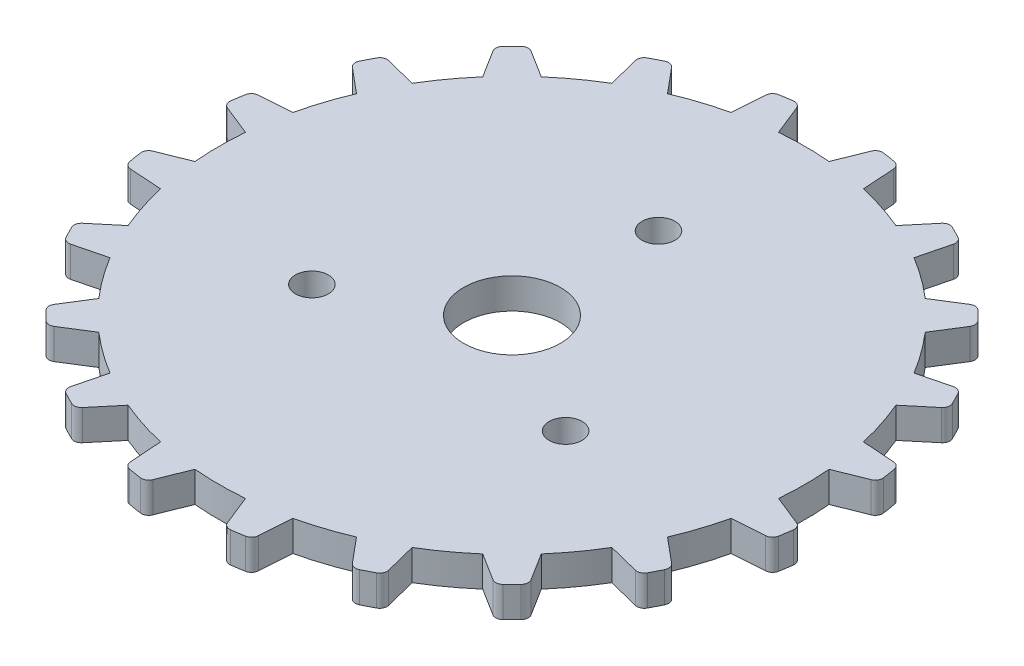
from build123d import *

# Parameters (mm, degrees)
BOSS_EXTRUDE1_DEPTH = 2.5
FILLET1_R           = 0.6
SKETCH5_R           = 1.35
CUT_EXTRUDE4_DEPTH  = 3.5
SKETCH6_R           = 3.96875
CUT_EXTRUDE5_DEPTH  = 3.5


with BuildPart() as part:
    # Sketch1 → Boss-Extrude1 (new body)
    with BuildSketch(Plane(origin=(0, 0, 0), x_dir=(1, 0, 0), z_dir=(0, 1, 0))):
        with BuildLine():
            Line((-2.069685574, 23.903244449), (-3.232226288, 26.798460531))
            ThreePointArc((-3.232226288, 26.798460531), (-4.222590109, 26.66035458), (-5.207159099, 26.485661549))
            Line((-5.207159099, 26.485661549), (-5.418128963, 23.372902518))
            ThreePointArc((-5.418128963, 23.372902518), (-7.414149843, 22.818393363), (-9.354896707, 22.093768379))
            Line((-9.354896707, 22.093768379), (-11.3552096, 24.488037662))
            ThreePointArc((-11.3552096, 24.488037662), (-12.25442448, 24.050651847), (-13.136822119, 23.580260351))
            Line((-13.136822119, 23.580260351), (-12.375570942, 20.554657318))
            ThreePointArc((-12.375570942, 20.554657318), (-14.102546855, 19.410483399), (-15.724385372, 18.121600323))
            Line((-15.724385372, 18.121600323), (-18.36666588, 19.780555048))
            ThreePointArc((-18.36666588, 19.780555048), (-19.086710402, 19.086703739), (-19.78056146, 18.366658976))
            Line((-19.78056146, 18.366658976), (-18.121605812, 15.724379046))
            ThreePointArc((-18.121605812, 15.724379046), (-19.410488322, 14.102540079), (-20.554661637, 12.375563767))
            Line((-20.554661637, 12.375563767), (-23.580264936, 13.136813888))
            ThreePointArc((-23.580264936, 13.136813888), (-24.050656124, 12.254416085), (-24.488041625, 11.355201052))
            Line((-24.488041625, 11.355201052), (-22.093771644, 9.354888995))
            ThreePointArc((-22.093771644, 9.354888995), (-22.818395951, 7.414141878), (-23.37290441, 5.418120804))
            Line((-23.37290441, 5.418120804), (-26.485663367, 5.207149854))
            ThreePointArc((-26.485663367, 5.207149854), (-26.660356054, 4.222580803), (-26.798461659, 3.232216933))
            Line((-26.798461659, 3.232216933), (-23.903245172, 2.06967723))
            ThreePointArc((-23.903245172, 2.06967723), (-23.99268, -4.188e-06), (-23.903244449, -2.069685574))
            Line((-23.903244449, -2.069685574), (-26.798460531, -3.232226288))
            ThreePointArc((-26.798460531, -3.232226288), (-26.66035458, -4.222590109), (-26.485661549, -5.207159099))
            Line((-26.485661549, -5.207159099), (-23.372902518, -5.418128963))
            ThreePointArc((-23.372902518, -5.418128963), (-22.818393363, -7.414149843), (-22.093768379, -9.354896707))
            Line((-22.093768379, -9.354896707), (-24.488037662, -11.3552096))
            ThreePointArc((-24.488037662, -11.3552096), (-24.050651847, -12.25442448), (-23.580260351, -13.136822119))
            Line((-23.580260351, -13.136822119), (-20.554657318, -12.375570942))
            ThreePointArc((-20.554657318, -12.375570942), (-19.410483399, -14.102546855), (-18.121600323, -15.724385372))
            Line((-18.121600323, -15.724385372), (-19.780555048, -18.36666588))
            ThreePointArc((-19.780555048, -18.36666588), (-19.086703739, -19.086710402), (-18.366658976, -19.78056146))
            Line((-18.366658976, -19.78056146), (-15.724379046, -18.121605812))
            ThreePointArc((-15.724379046, -18.121605812), (-14.102540079, -19.410488322), (-12.375563767, -20.554661637))
            Line((-12.375563767, -20.554661637), (-13.136813888, -23.580264936))
            ThreePointArc((-13.136813888, -23.580264936), (-12.254416085, -24.050656124), (-11.355201052, -24.488041625))
            Line((-11.355201052, -24.488041625), (-9.354888995, -22.093771644))
            ThreePointArc((-9.354888995, -22.093771644), (-7.414141878, -22.818395951), (-5.418120804, -23.37290441))
            Line((-5.418120804, -23.37290441), (-5.207149854, -26.485663367))
            ThreePointArc((-5.207149854, -26.485663367), (-4.222580803, -26.660356054), (-3.232216933, -26.798461659))
            Line((-3.232216933, -26.798461659), (-2.06967723, -23.903245172))
            ThreePointArc((-2.06967723, -23.903245172), (4.188e-06, -23.99268), (2.069685574, -23.903244449))
            Line((2.069685574, -23.903244449), (3.232226288, -26.798460531))
            ThreePointArc((3.232226288, -26.798460531), (4.222590109, -26.66035458), (5.207159099, -26.485661549))
            Line((5.207159099, -26.485661549), (5.418128963, -23.372902518))
            ThreePointArc((5.418128963, -23.372902518), (7.414149843, -22.818393363), (9.354896707, -22.093768379))
            Line((9.354896707, -22.093768379), (11.3552096, -24.488037662))
            ThreePointArc((11.3552096, -24.488037662), (12.25442448, -24.050651847), (13.136822119, -23.580260351))
            Line((13.136822119, -23.580260351), (12.375570942, -20.554657318))
            ThreePointArc((12.375570942, -20.554657318), (14.102546855, -19.410483399), (15.724385372, -18.121600323))
            Line((15.724385372, -18.121600323), (18.36666588, -19.780555048))
            ThreePointArc((18.36666588, -19.780555048), (19.086710402, -19.086703739), (19.78056146, -18.366658976))
            Line((19.78056146, -18.366658976), (18.121605812, -15.724379046))
            ThreePointArc((18.121605812, -15.724379046), (19.410488322, -14.102540079), (20.554661637, -12.375563767))
            Line((20.554661637, -12.375563767), (23.580264936, -13.136813888))
            ThreePointArc((23.580264936, -13.136813888), (24.050656124, -12.254416085), (24.488041625, -11.355201052))
            Line((24.488041625, -11.355201052), (22.093771644, -9.354888995))
            ThreePointArc((22.093771644, -9.354888995), (22.818395951, -7.414141878), (23.37290441, -5.418120804))
            Line((23.37290441, -5.418120804), (26.485663367, -5.207149854))
            ThreePointArc((26.485663367, -5.207149854), (26.660356054, -4.222580803), (26.798461659, -3.232216933))
            Line((26.798461659, -3.232216933), (23.903245172, -2.06967723))
            ThreePointArc((23.903245172, -2.06967723), (23.99268, 4.188e-06), (23.903244449, 2.069685574))
            Line((23.903244449, 2.069685574), (26.798460531, 3.232226288))
            ThreePointArc((26.798460531, 3.232226288), (26.66035458, 4.222590109), (26.485661549, 5.207159099))
            Line((26.485661549, 5.207159099), (23.372902518, 5.418128963))
            ThreePointArc((23.372902518, 5.418128963), (22.818393363, 7.414149843), (22.093768379, 9.354896707))
            Line((22.093768379, 9.354896707), (24.488037662, 11.3552096))
            ThreePointArc((24.488037662, 11.3552096), (24.050651847, 12.25442448), (23.580260351, 13.136822119))
            Line((23.580260351, 13.136822119), (20.554657318, 12.375570942))
            ThreePointArc((20.554657318, 12.375570942), (19.410483399, 14.102546855), (18.121600323, 15.724385372))
            Line((18.121600323, 15.724385372), (19.780555048, 18.36666588))
            ThreePointArc((19.780555048, 18.36666588), (19.086703739, 19.086710402), (18.366658976, 19.78056146))
            Line((18.366658976, 19.78056146), (15.724379046, 18.121605812))
            ThreePointArc((15.724379046, 18.121605812), (14.102540079, 19.410488322), (12.375563767, 20.554661637))
            Line((12.375563767, 20.554661637), (13.136813888, 23.580264936))
            ThreePointArc((13.136813888, 23.580264936), (12.254416085, 24.050656124), (11.355201052, 24.488041625))
            Line((11.355201052, 24.488041625), (9.354888995, 22.093771644))
            ThreePointArc((9.354888995, 22.093771644), (7.414141878, 22.818395951), (5.418120804, 23.37290441))
            Line((5.418120804, 23.37290441), (5.207149854, 26.485663367))
            ThreePointArc((5.207149854, 26.485663367), (4.222580803, 26.660356054), (3.232216933, 26.798461659))
            Line((3.232216933, 26.798461659), (2.06967723, 23.903245172))
            ThreePointArc((2.06967723, 23.903245172), (-4.188e-06, 23.99268), (-2.069685574, 23.903244449))
        make_face()
    extrude(amount=-BOSS_EXTRUDE1_DEPTH)

    # Fillet1
    fillet1_edges = [part.edges().sort_by_distance(p)[0] for p in [
        (3.232216933, -1.25, -26.798461659),
        (5.207149854, -1.25, -26.485663367),
        (11.355201052, -1.25, -24.488041625),
        (13.136813888, -1.25, -23.580264936),
        (18.366658976, -1.25, -19.78056146),
        (19.780555048, -1.25, -18.36666588),
        (23.580260351, -1.25, -13.136822119),
        (24.488037662, -1.25, -11.3552096),
        (26.485661549, -1.25, -5.207159099),
        (26.798460531, -1.25, -3.232226288),
        (26.798461659, -1.25, 3.232216933),
        (26.485663367, -1.25, 5.207149854),
        (24.488041625, -1.25, 11.355201052),
        (23.580264936, -1.25, 13.136813888),
        (19.78056146, -1.25, 18.366658976),
        (18.36666588, -1.25, 19.780555048),
        (13.136822119, -1.25, 23.580260351),
        (11.3552096, -1.25, 24.488037662),
        (5.207159099, -1.25, 26.485661549),
        (3.232226288, -1.25, 26.798460531),
        (-3.232216933, -1.25, 26.798461659),
        (-5.207149854, -1.25, 26.485663367),
        (-11.355201052, -1.25, 24.488041625),
        (-13.136813888, -1.25, 23.580264936),
        (-18.366658976, -1.25, 19.78056146),
        (-19.780555048, -1.25, 18.36666588),
        (-23.580260351, -1.25, 13.136822119),
        (-24.488037662, -1.25, 11.3552096),
        (-26.485661549, -1.25, 5.207159099),
        (-26.798460531, -1.25, 3.232226288),
        (-26.798461659, -1.25, -3.232216933),
        (-26.485663367, -1.25, -5.207149854),
        (-24.488041625, -1.25, -11.355201052),
        (-23.580264936, -1.25, -13.136813888),
        (-19.78056146, -1.25, -18.366658976),
        (-18.36666588, -1.25, -19.780555048),
        (-13.136822119, -1.25, -23.580260351),
        (-11.3552096, -1.25, -24.488037662),
        (-5.207159099, -1.25, -26.485661549),
        (-3.232226288, -1.25, -26.798460531),
    ]]
    fillet(fillet1_edges, radius=FILLET1_R)

    # Sketch5 → Cut-Extrude4 (cut, through all)
    with BuildSketch(Plane(origin=(0, 0, 0), x_dir=(1, 0, 0), z_dir=(0, 1, 0))):
        with Locations((0, 12)):
            Circle(SKETCH5_R)
        with Locations((10.392304845, -6)):
            Circle(SKETCH5_R)
        with Locations((-10.392304845, -6)):
            Circle(SKETCH5_R)
    extrude(amount=-CUT_EXTRUDE4_DEPTH, mode=Mode.SUBTRACT)

    # Sketch6 → Cut-Extrude5 (cut, through all)
    with BuildSketch(Plane(origin=(0, 0, 0), x_dir=(1, 0, 0), z_dir=(0, 1, 0))):
        Circle(SKETCH6_R)
    extrude(amount=-CUT_EXTRUDE5_DEPTH, mode=Mode.SUBTRACT)


solid = part.part
